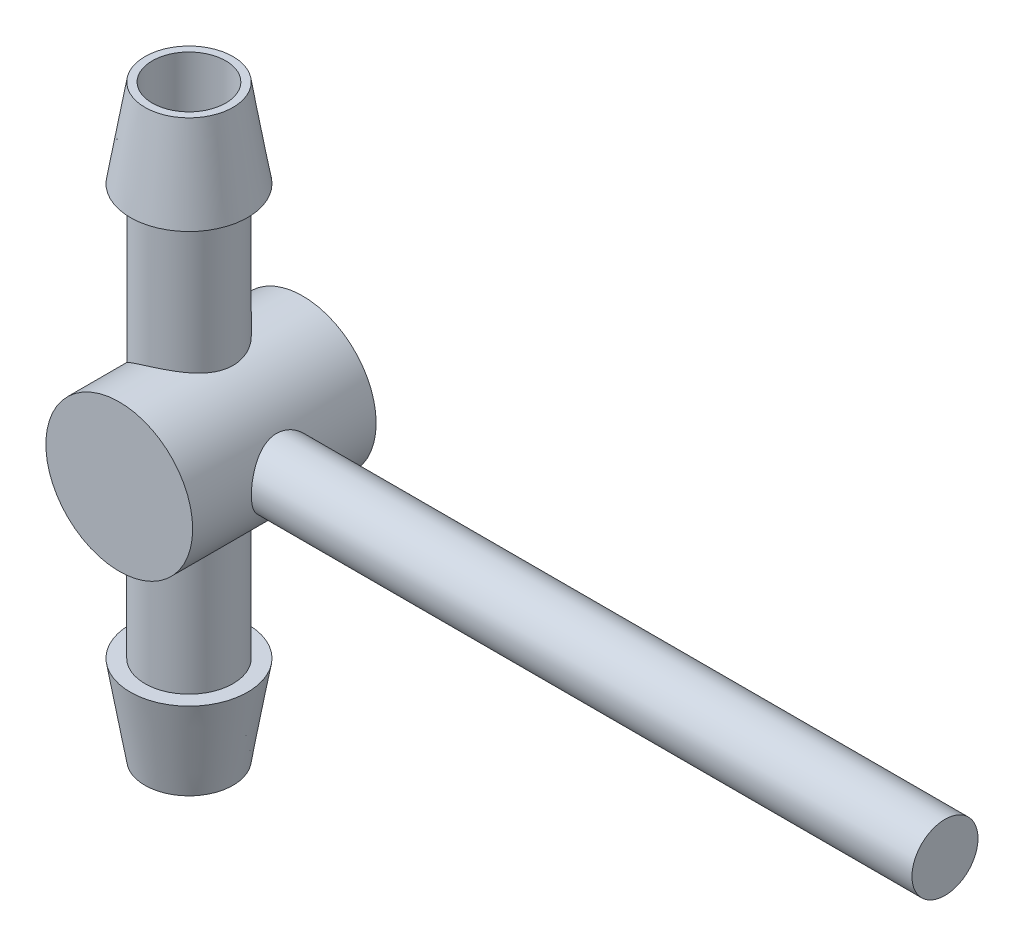
from build123d import *

# Parameters (mm, degrees)
SKETCH1_R           = 5
BOSS_EXTRUDE1_DEPTH = 6.25
SKETCH2_R           = 3
BOSS_EXTRUDE2_DEPTH = 20
SKETCH3_R           = 2.25
BOSS_EXTRUDE3_DEPTH = 50
SKETCH4_R           = 2.5
CUT_EXTRUDE1_DEPTH  = 40
CUT_EXTRUDE2_REACH  = 14.5
SKETCH5_R           = 3.75
SKETCH7_R           = 5
BOSS_EXTRUDE4_DEPTH = 2.5


with BuildPart() as part:
    # Sketch1 → Boss-Extrude1 (new body, symmetric)
    with BuildSketch(Plane.XY):
        Circle(SKETCH1_R)
    extrude(amount=BOSS_EXTRUDE1_DEPTH, both=True)

    # Sketch2 → Boss-Extrude2 (add, symmetric)
    with BuildSketch(Plane(origin=(0, 0, 0), x_dir=(1, 0, 0), z_dir=(0, 1, 0))):
        with Locations((-1.5, 0)):
            Circle(SKETCH2_R)
    extrude(amount=BOSS_EXTRUDE2_DEPTH, both=True)

    # Sketch3 → Boss-Extrude3 (add)
    with BuildSketch(Plane(origin=(0, 0, 0), x_dir=(0, 0, -1), z_dir=(1, 0, 0))):
        Circle(SKETCH3_R)
    extrude(amount=BOSS_EXTRUDE3_DEPTH)

    # Sketch4 → Cut-Extrude1 (cut)
    with BuildSketch(Plane.XZ.offset(20)):
        with Locations((-1.5, 0)):
            Circle(SKETCH4_R)
    extrude(amount=-CUT_EXTRUDE1_DEPTH, mode=Mode.SUBTRACT)

    # Sketch5 → Cut-Extrude2 (cut, up to next)
    with BuildSketch(Plane.XY.offset(6.25), mode=Mode.PRIVATE) as cut_extrude2_sk1:
        Circle(SKETCH5_R)
    cut_extrude2_tool1 = extrude(cut_extrude2_sk1.sketch, amount=-CUT_EXTRUDE2_REACH, mode=Mode.PRIVATE) & part.part
    add(cut_extrude2_tool1.solids().sort_by_distance((0, 0, 6.25))[0], mode=Mode.SUBTRACT)

    # Sketch7 → Boss-Extrude4 (add)
    with BuildSketch(Plane.XY.offset(6.25)):
        Circle(SKETCH7_R)
    extrude(amount=-BOSS_EXTRUDE4_DEPTH)

    # Sketch6 → Revolve1 (revolve)
    with BuildSketch(Plane.XY):
        Polygon((1.5, 14), (1.5, 20), (2.5, 14), align=None)
        Polygon((1.5, -20), (2.5, -14), (1.5, -14), align=None)
    revolve(axis=Axis((-1.5, 20, 0), (0, -1, 0)))


solid = part.part
